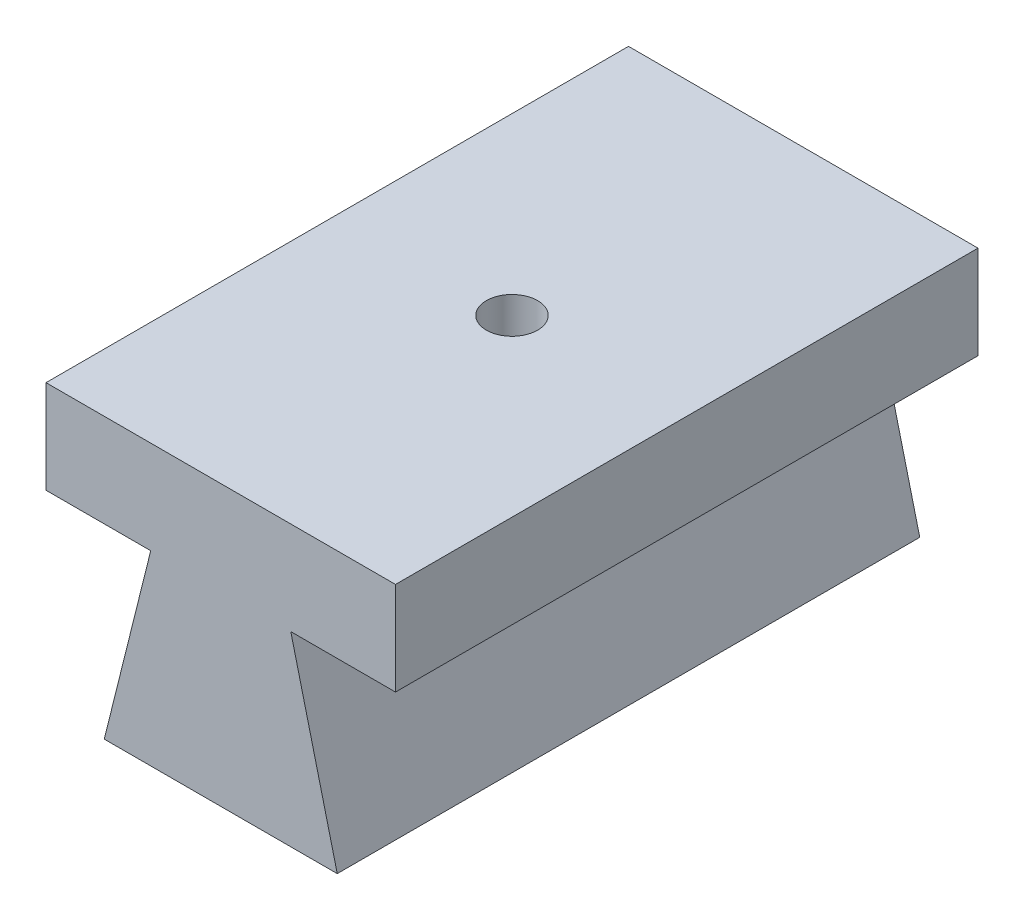
from build123d import *

# Parameters (mm, degrees)
BASE_EXTRUDE_DEPTH = 15.875
SKETCH3_R          = 1.397
CUT_EXTRUDE2_DEPTH = 12.7


with BuildPart() as part:
    # Sketch1 → Base-Extrude (new body, symmetric)
    with BuildSketch(Plane.XY):
        Polygon((6.35, 0), (-6.35, 0), (-3.816827491, 10.16), (-9.525, 10.16), (-9.525, 15.24), (9.525, 15.24), (9.525, 10.16), (3.816827491, 10.16), align=None)
    extrude(amount=BASE_EXTRUDE_DEPTH, both=True)

    # Sketch3 → Cut-Extrude2 (cut)
    with BuildSketch(Plane(origin=(0, 15.24, 0), x_dir=(-1, 0, 0), z_dir=(0, 1, 0))):
        Circle(SKETCH3_R)
    extrude(amount=-CUT_EXTRUDE2_DEPTH, mode=Mode.SUBTRACT)


solid = part.part
